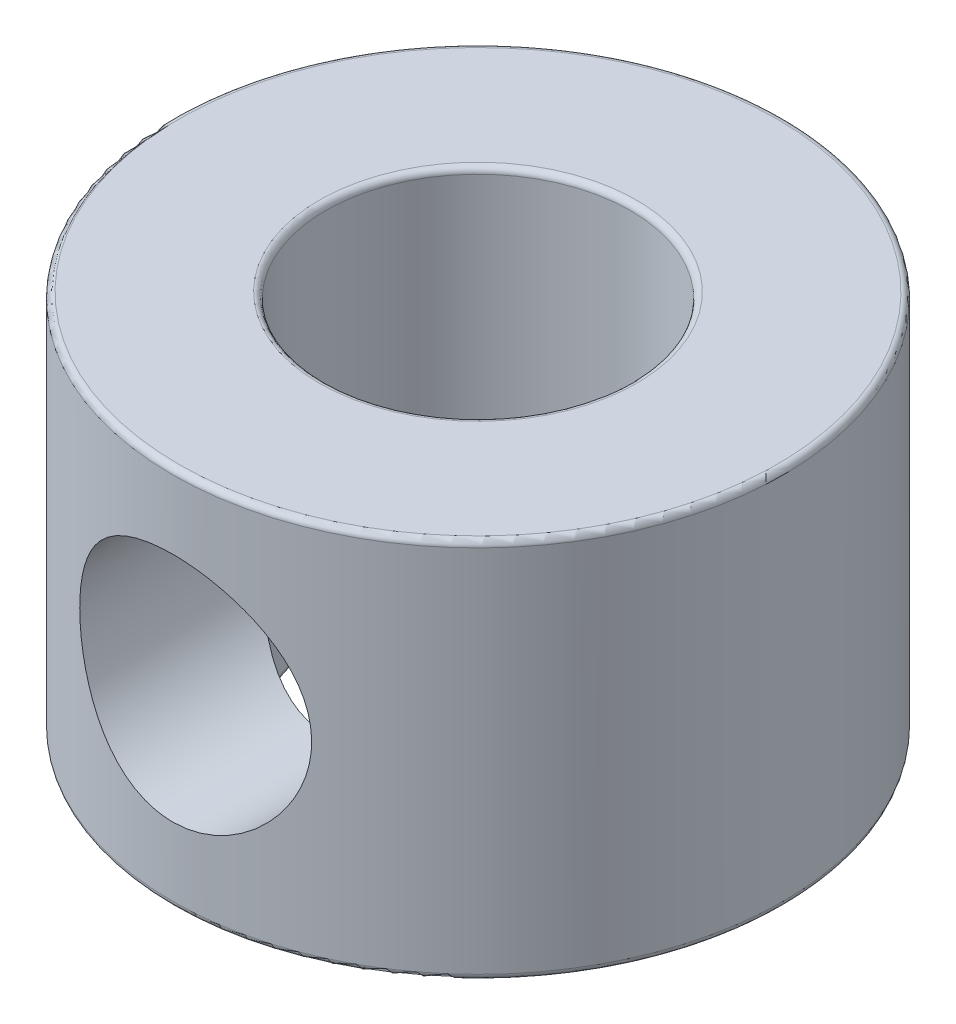
from build123d import *

# Parameters (mm, degrees)
SKETCH_1_W          = 6.35
SKETCH_1_H          = 7.9375
HOLE_WIZARD_1_D     = 6.35
HOLE_WIZARD_1_DEPTH = 7.9375
SKETCH_4_W          = 2.413
SKETCH_4_H          = 4.286494245
FILLET_1_R          = 0.127


with BuildPart() as part:
    # 草图1 → 旋转1 (revolve)
    with BuildSketch(Plane(origin=(0, 0, 0), x_dir=(-1, 0, 0), z_dir=(0, 0, -1))):
        with Locations((-3.175, 0)):
            Rectangle(SKETCH_1_W, SKETCH_1_H)
    revolve(axis=Axis((0, -3.96875, 0), (0, 1, 0)))

    # 孔1
    with Locations(Plane(origin=(0, -3.96875, 0), x_dir=(-1, 0, 0), z_dir=(0, -1, 0))):
        with Locations((0, 0)):
            Hole(HOLE_WIZARD_1_D / 2, depth=HOLE_WIZARD_1_DEPTH)

    # 草图4 → 孔2 (revolve, cut)
    with BuildSketch(Plane(origin=(0, 0, 2.063505755), x_dir=(0, 1, 0), z_dir=(1, 0, 0))):
        with Locations((1.2065, 2.143247123)):
            Rectangle(SKETCH_4_W, SKETCH_4_H)
    revolve(axis=Axis((0, 0, 112.063505755), (0, 0, -1)), mode=Mode.SUBTRACT)

    # 圆角1
    fillet_1_edges = [part.edges().sort_by_distance(p)[0] for p in [
        (-3.175, -3.96875, 0),
        (-3.175, 3.96875, 0),
        (-6.35, 3.96875, 0),
        (-6.35, -3.96875, 0),
    ]]
    fillet(fillet_1_edges, radius=FILLET_1_R)


solid = part.part
